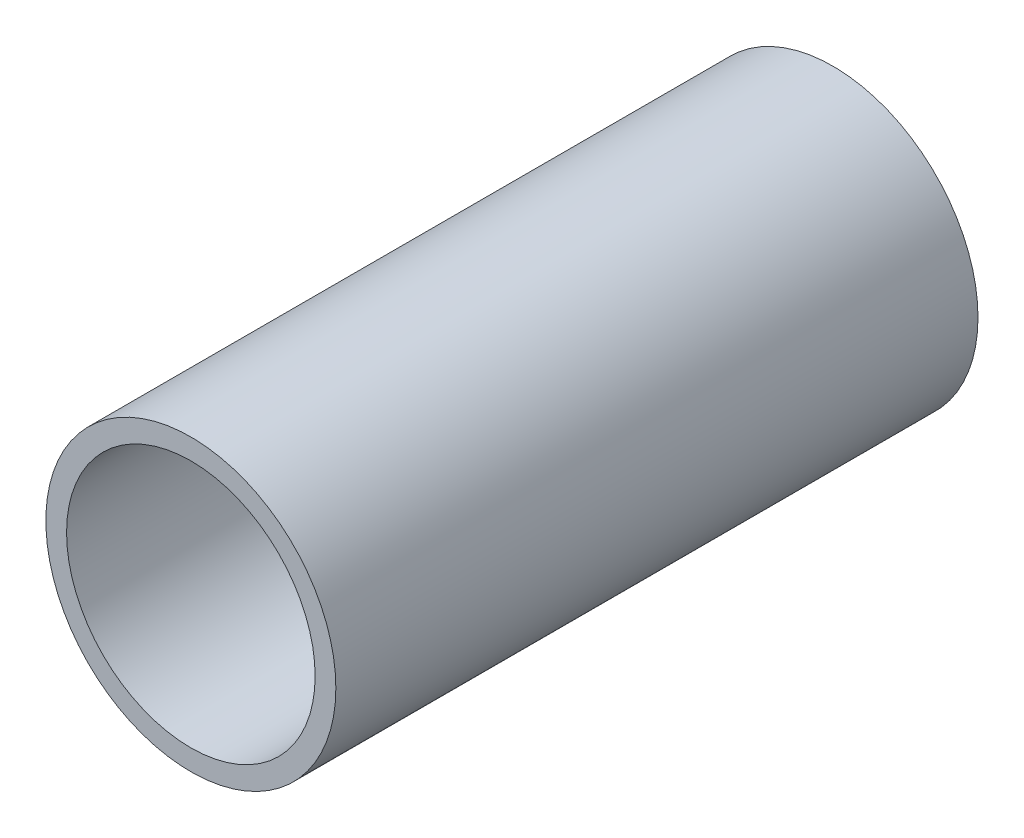
from build123d import *

# Parameters (mm, degrees)
SKETCH1_R           = 44.45
SKETCH1_R_2         = 38.1
BOSS_EXTRUDE1_DEPTH = 98.425


with BuildPart() as part:
    # Sketch1 → Boss-Extrude1 (new body, symmetric)
    with BuildSketch(Plane.XY):
        Circle(SKETCH1_R)
        Circle(SKETCH1_R_2, mode=Mode.SUBTRACT)
    extrude(amount=BOSS_EXTRUDE1_DEPTH, both=True)


solid = part.part
